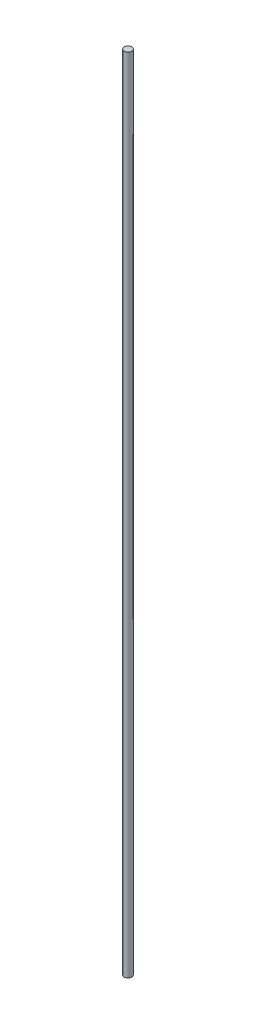
from build123d import *

# Parameters (mm, degrees)
ESQUISSE1_R      = 1.5
EXTRUSION1_DEPTH = 320


with BuildPart() as part:
    # Esquisse1 → Extrusion1 (new body)
    with BuildSketch(Plane(origin=(0, 0, 0), x_dir=(1, 0, 0), z_dir=(0, 1, 0))):
        with Locations(Location((0, 0, 0), (0, 0, 270))):  # turned: the seam where the file's is
            Circle(ESQUISSE1_R)
    extrude(amount=EXTRUSION1_DEPTH)


solid = part.part
